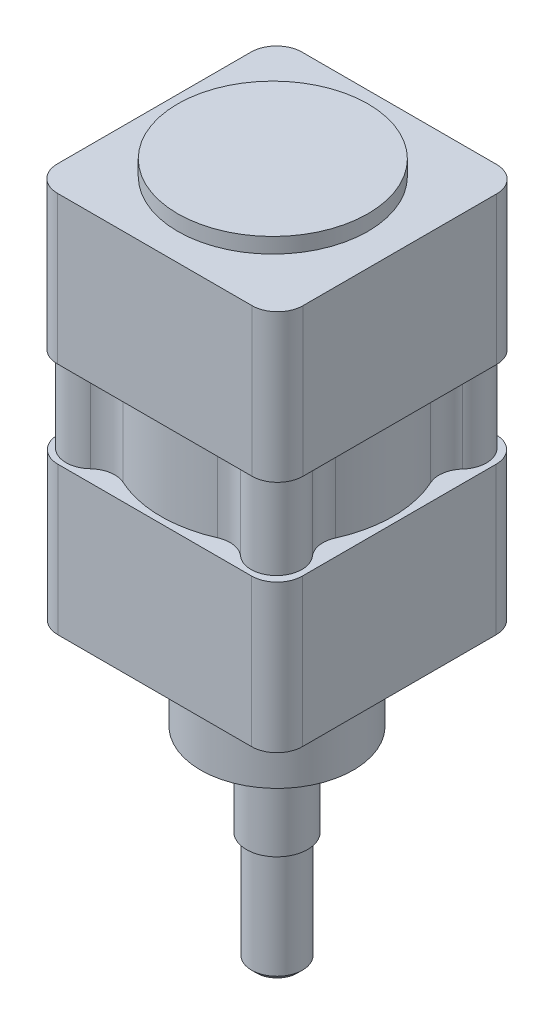
from build123d import *

# Parameters (mm, degrees)
SALIENTE_EXTRUIR1_DEPTH  = 29
CROQUIS2_R               = 22.770045983
SALIENTE_EXTRUIR2_DEPTH  = 46
CROQUIS3_R               = 16
CORTAR_EXTRUIR2_DEPTH    = 90
CROQUIS4_R               = 5
SALIENTE_EXTRUIR3_DEPTH  = 65
REDONDEO1_R              = 5
SALIENTE_EXTRUIR4_DEPTH  = 29
CROQUIS6_R               = 18.676439513
SALIENTE_EXTRUIR5_DEPTH  = 3
CROQUIS7_R               = 3
CORTAR_EXTRUIR3_DEPTH    = 25
CROQUIS8_R               = 15
SALIENTE_EXTRUIR7_DEPTH  = 18
CROQUIS9_R               = 6
SALIENTE_EXTRUIR9_DEPTH  = 18
CROQUIS10_R              = 5
SALIENTE_EXTRUIR11_DEPTH = 22
CHAFL_N1_SIZE            = 1


with BuildPart() as part:
    # Croquis1 → Saliente-Extruir1 (new body)
    with BuildSketch(Plane(origin=(0, 0, 0), x_dir=(1, 0, 0), z_dir=(0, 1, 0))):
        with BuildLine():
            Line((-19, -24), (19, -24))
            ThreePointArc((19, -24), (22.535533906, -22.535533906), (24, -19))
            Line((24, -19), (24, 19))
            ThreePointArc((24, 19), (22.535533906, 22.535533906), (19, 24))
            Line((19, 24), (-19, 24))
            ThreePointArc((-19, 24), (-22.535533906, 22.535533906), (-24, 19))
            Line((-24, 19), (-24, -19))
            ThreePointArc((-24, -19), (-22.535533906, -22.535533906), (-19, -24))
        make_face()
    extrude(amount=SALIENTE_EXTRUIR1_DEPTH)

    # Croquis2 → Saliente-Extruir2 (add)
    with BuildSketch(Plane.XZ):
        Circle(CROQUIS2_R)
    extrude(amount=-SALIENTE_EXTRUIR2_DEPTH)

    # Croquis3 → Cortar-Extruir2 (cut)
    with BuildSketch(Plane(origin=(0, 46, 0), x_dir=(1, 0, 0), z_dir=(0, 1, 0))):
        Circle(CROQUIS3_R)
    extrude(amount=-CORTAR_EXTRUIR2_DEPTH, mode=Mode.SUBTRACT)

    # Croquis4 → Saliente-Extruir3 (add)
    with BuildSketch(Plane.XZ):
        with Locations((17.845802116, 17.948364197)):
            Circle(CROQUIS4_R)
        with Locations((-18.461174602, 17.948364197)):
            Circle(CROQUIS4_R)
        with Locations((-18.461174602, -18.25605044)):
            Circle(CROQUIS4_R)
        with Locations((17.845802116, -18.25605044)):
            Circle(CROQUIS4_R)
    extrude(amount=-SALIENTE_EXTRUIR3_DEPTH)

    # Redondeo1
    redondeo1_edges = [part.edges().sort_by_distance(p)[0] for p in [
        (12.911388794, 37.5, 18.755560068),
        (18.681261941, 37.5, 13.018657625),
        (-18.725226903, 37.5, 12.955341427),
        (-13.477569022, 37.5, 18.35293239),
        (-13.462342306, 37.5, -18.364104489),
        (-18.513370775, 37.5, -13.256322892),
        (18.484196311, 37.5, -13.296972617),
        (12.873497796, 37.5, -18.78158802),
    ]]
    fillet(redondeo1_edges, radius=REDONDEO1_R)

    # Croquis5 → Saliente-Extruir4 (add)
    with BuildSketch(Plane(origin=(0, 46, 0), x_dir=(1, 0, 0), z_dir=(0, 1, 0))):
        with BuildLine():
            Line((-19.102089064, -23.999526983), (19.102089064, -23.999526983))
            ThreePointArc((19.102089064, -23.999526983), (22.63762297, -22.535060889), (24.102089064, -18.999526983))
            Line((24.102089064, -18.999526983), (24.102089064, 18.999526983))
            ThreePointArc((24.102089064, 18.999526983), (22.63762297, 22.535060889), (19.102089064, 23.999526983))
            Line((19.102089064, 23.999526983), (-19.102089064, 23.999526983))
            ThreePointArc((-19.102089064, 23.999526983), (-22.63762297, 22.535060889), (-24.102089064, 18.999526983))
            Line((-24.102089064, 18.999526983), (-24.102089064, -18.999526983))
            ThreePointArc((-24.102089064, -18.999526983), (-22.63762297, -22.535060889), (-19.102089064, -23.999526983))
        make_face()
    extrude(amount=SALIENTE_EXTRUIR4_DEPTH)

    # Croquis6 → Saliente-Extruir5 (add)
    with BuildSketch(Plane(origin=(0, 75, 0), x_dir=(1, 0, 0), z_dir=(0, 1, 0))):
        with Locations((-0.820496649, 0)):
            Circle(CROQUIS6_R)
    extrude(amount=SALIENTE_EXTRUIR5_DEPTH)

    # Croquis7 → Cortar-Extruir3 (cut)
    with BuildSketch(Plane(origin=(0, 0, 0), x_dir=(1, 0, 0), z_dir=(0, 1, 0))):
        with Locations((-16.25, 16.25)):
            Circle(CROQUIS7_R)
        with Locations((16.25, 16.25)):
            Circle(CROQUIS7_R)
        with Locations((16.25, -16.25)):
            Circle(CROQUIS7_R)
        with Locations((-16.25, -16.25)):
            Circle(CROQUIS7_R)
    extrude(amount=CORTAR_EXTRUIR3_DEPTH, mode=Mode.SUBTRACT)


with BuildPart() as body_2:
    # Croquis8 → Saliente-Extruir7 (new body)
    with BuildSketch(Plane(origin=(0, 0, 0), x_dir=(1, 0, 0), z_dir=(0, 1, 0))):
        Circle(CROQUIS8_R)
    extrude(amount=-SALIENTE_EXTRUIR7_DEPTH)


with BuildPart() as body_3:
    # Croquis9 → Saliente-Extruir9 (new body)
    with BuildSketch(Plane.XZ.offset(18)):
        Circle(CROQUIS9_R)
    extrude(amount=SALIENTE_EXTRUIR9_DEPTH)


with BuildPart() as body_4:
    # Croquis10 → Saliente-Extruir11 (new body)
    with BuildSketch(Plane.XZ.offset(36)):
        Circle(CROQUIS10_R)
    extrude(amount=SALIENTE_EXTRUIR11_DEPTH)

    # Chaflán1
    chafl_n1_edges = [body_4.edges().sort_by_distance(p)[0] for p in [
        (-5, -58, 0),
    ]]
    chamfer(chafl_n1_edges, length=CHAFL_N1_SIZE)


solid = Compound([part.part, body_2.part, body_3.part, body_4.part])
